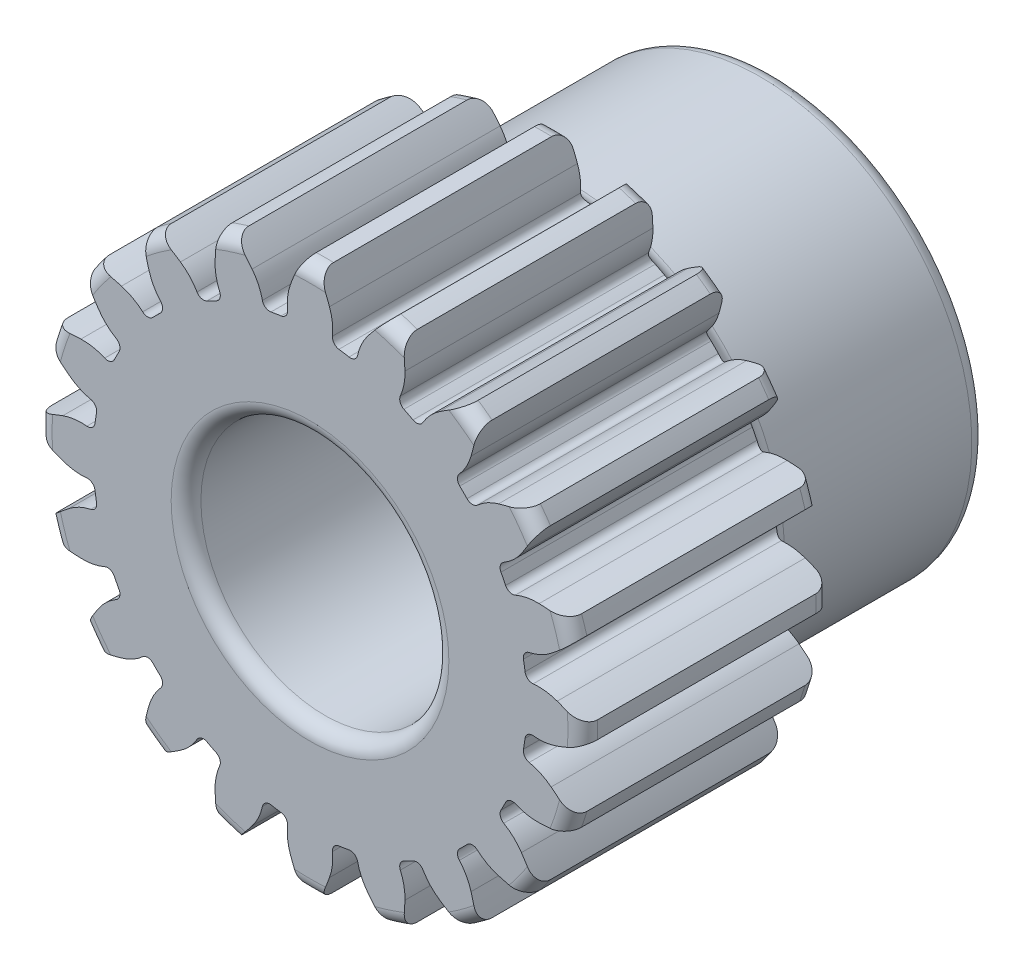
from build123d import *

# Parameters (mm, degrees)
CUT_EXTRUDE1_START = -24.8252
CUT_EXTRUDE1_DEPTH = 25.8252
CIRPATTERN1_COUNT  = 20


with BuildPart() as part:
    # Sketch3 → Revolve1 (revolve)
    with BuildSketch(Plane(origin=(0, 0, 0), x_dir=(0, 0, -1), z_dir=(1, 0, 0))):
        with BuildLine():
            Line((11.1506, 6.35), (-11.1506, 6.35))
            ThreePointArc((-11.1506, 6.35), (-11.689415367, 6.573184633), (-11.9126, 7.112))
            Line((-11.9126, 7.112), (-11.9126, 13.208))
            ThreePointArc((-11.9126, 13.208), (-11.689415367, 13.746815367), (-11.1506, 13.97))
            Line((-11.1506, 13.97), (0.0254, 13.97))
            ThreePointArc((0.0254, 13.97), (0.564215367, 13.746815367), (0.7874, 13.208))
            Line((0.7874, 13.208), (0.7874, 11.5951))
            ThreePointArc((0.7874, 11.5951), (1.010584633, 11.056284633), (1.5494, 10.8331))
            Line((1.5494, 10.8331), (11.1506, 10.8331))
            ThreePointArc((11.1506, 10.8331), (11.689415367, 10.609915367), (11.9126, 10.0711))
            Line((11.9126, 10.0711), (11.9126, 7.112))
            ThreePointArc((11.9126, 7.112), (11.689415367, 6.573184633), (11.1506, 6.35))
        make_face()
    revolve(axis=Axis((0, 0, -11.9126), (0, 0, 1)))

    # Sketch4 → Cut-Extrude1 (cut)
    with BuildSketch(Plane.XY.offset(11.9126).offset(CUT_EXTRUDE1_START)):
        with BuildLine():
            ThreePointArc((3.895229119, 13.415964002), (2.185389477, 13.798006118), (0.441177837, 13.963031982))
            ThreePointArc((0.441177837, 13.963031982), (0.736386787, 13.31943776), (0.996432841, 12.660849955))
            ThreePointArc((0.996432841, 12.660849955), (1.142873547, 12.053827159), (1.150386248, 11.429435364))
            ThreePointArc((1.150386248, 11.429435364), (1.230481983, 11.155130453), (1.478770205, 11.01366855))
            ThreePointArc((1.478770205, 11.01366855), (1.738377993, 10.975686685), (1.997016713, 10.931586367))
            ThreePointArc((1.997016713, 10.931586367), (2.276866976, 10.989399351), (2.437807426, 11.225527881))
            ThreePointArc((2.437807426, 11.225527881), (2.637900105, 11.817038215), (2.964753853, 12.349098534))
            ThreePointArc((2.964753853, 12.349098534), (3.415587171, 12.895094106), (3.895229119, 13.415964002))
        make_face()
    cut_extrude1 = extrude(amount=CUT_EXTRUDE1_DEPTH, mode=Mode.SUBTRACT)

    # CirPattern1: Cut-Extrude1 ×20 about axis
    cirpattern1_axis = Axis((0, 0, 0), (0, 0, 1))
    for i in range(1, CIRPATTERN1_COUNT):
        add(cut_extrude1.rotate(cirpattern1_axis, i * 360 / CIRPATTERN1_COUNT), mode=Mode.SUBTRACT)


solid = part.part
